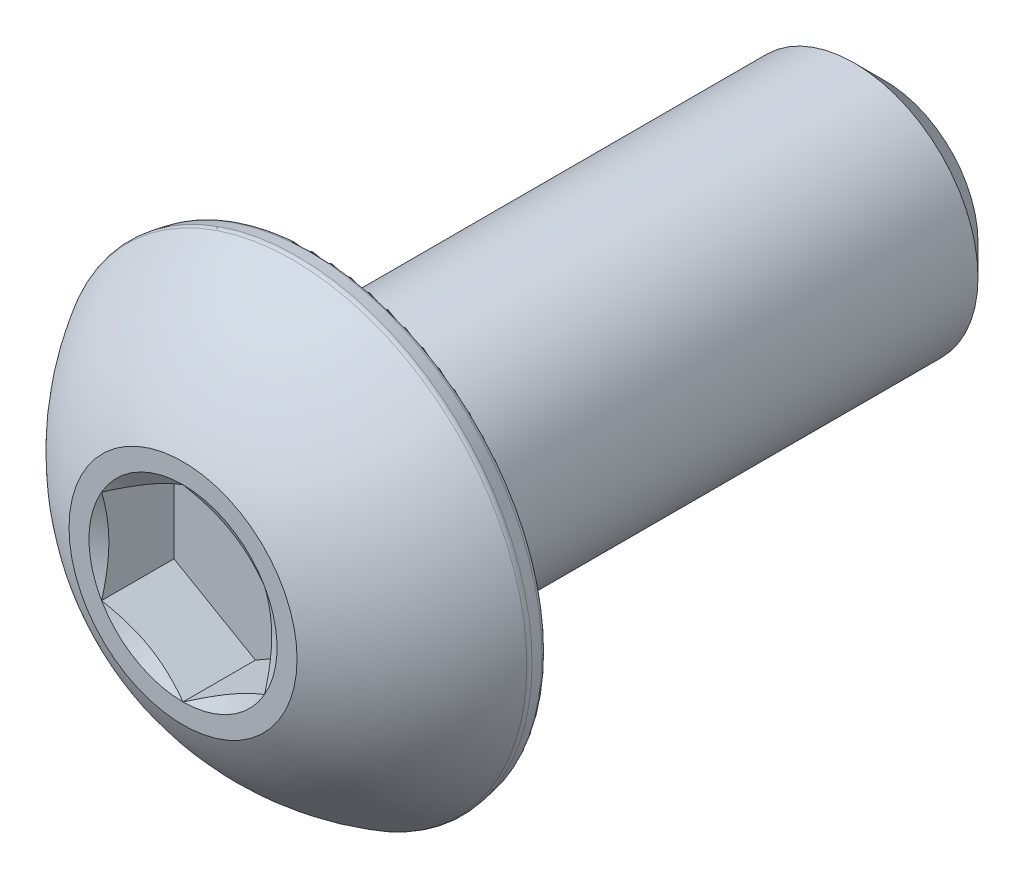
from build123d import *

# Parameters (mm, degrees)
CUT_EXTRUDE1_DEPTH = 1.41097
SKETCH5_R          = 1.833087105
CUT_EXTRUDE2_DEPTH = 1.41097
CUT_EXTRUDE2_DRAFT = -60
FILLET1_R          = 0.12827


with BuildPart() as part:
    # Sketch3 → Revolve1 (revolve)
    with BuildSketch(Plane(origin=(0, 0, 0), x_dir=(0, 0, -1), z_dir=(1, 0, 0))):
        with BuildLine():
            Line((-6.83895, 0), (-6.83895, 2.2225))
            ThreePointArc((-6.83895, 2.2225), (-5.93321038, 3.573966445), (-4.65836, 4.5847))
            Line((-4.65836, 4.5847), (-4.27355, 4.516847615))
            Line((-4.27355, 4.516847615), (-4.27355, 2.413))
            Line((-4.27355, 2.413), (6.2436375, 2.413))
            Line((6.2436375, 2.413), (6.83895, 1.8176875))
            Line((6.83895, 1.8176875), (6.83895, 0))
            Line((6.83895, 0), (-6.83895, 0))
        make_face()
    revolve(axis=Axis((0, 0, 6.83895), (0, 0, -1)))

    # Sketch4 → Cut-Extrude1 (cut)
    with BuildSketch(Plane.XY.offset(6.83895)):
        Polygon((-1.5875, -0.916543552), (0, -1.833087105), (1.5875, -0.916543552), (1.5875, 0.916543552), (0, 1.833087105), (-1.5875, 0.916543552), align=None)
    extrude(amount=-CUT_EXTRUDE1_DEPTH, mode=Mode.SUBTRACT)


with BuildPart() as cut_extrude2_tool:
    # Sketch5 → Cut-Extrude2 (with draft: the straight prism first)
    with BuildSketch(Plane.XY.offset(6.83895)):
        Circle(SKETCH5_R)
    extrude(amount=-CUT_EXTRUDE2_DEPTH)
    # Cut-Extrude2: the draft: its side faces are tilted about the plane it starts from
    cut_extrude2_sides = [cut_extrude2_tool.faces().sort_by_distance(p)[0] for p in [
        (-1.833087105, 0, 6.133465),
    ]]
    draft(cut_extrude2_sides, Plane.XY.offset(6.83895), CUT_EXTRUDE2_DRAFT)


with BuildPart() as part_1:
    add(part.part)

    # Cut-Extrude2: cut by cut_extrude2_tool
    add(cut_extrude2_tool.part, mode=Mode.SUBTRACT)

    # Fillet1
    fillet1_edges = [part_1.edges().sort_by_distance(p)[0] for p in [
        (0, -4.516847615, 4.27355),
        (0, -4.5847, 4.65836),
    ]]
    fillet(fillet1_edges, radius=FILLET1_R)


solid = part_1.part
